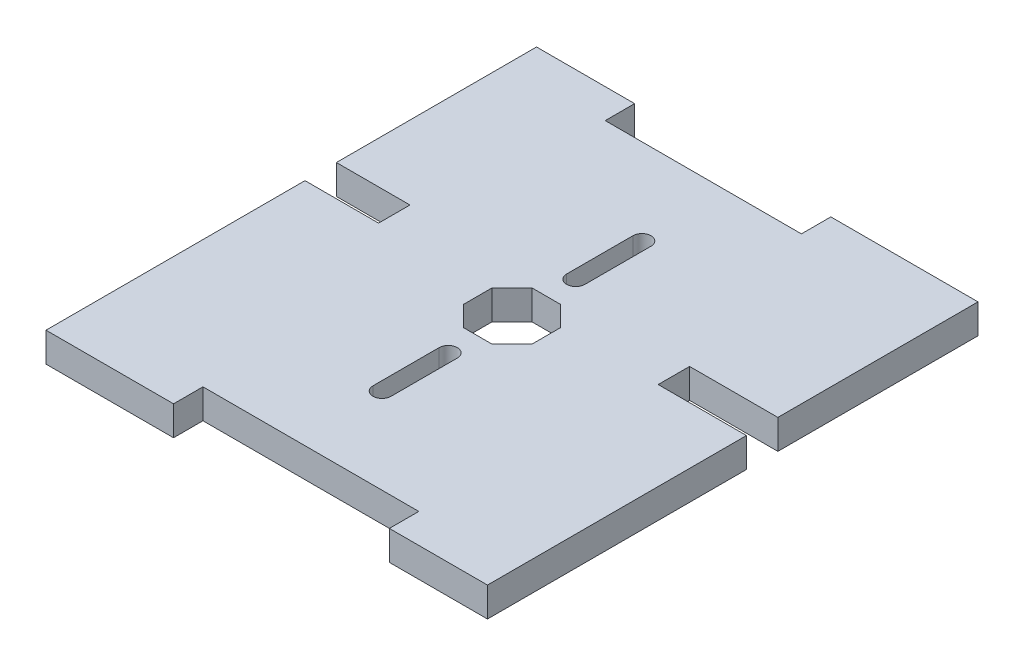
from build123d import *

# Parameters (mm, degrees)
SKETCH1_W           = 45
SKETCH1_H           = 50
BOSS_EXTRUDE1_DEPTH = 3
SKETCH2_W           = 20
SKETCH2_H           = 3
SKETCH2_W_2         = 22
SKETCH2_W_3         = 7.5
SKETCH2_W_4         = 9
CUT_EXTRUDE1_DEPTH  = 4
SKETCH4_W           = 7.5
SKETCH4_H           = 0.1
SKETCH4_W_2         = 9
CUT_EXTRUDE2_DEPTH  = 4


with BuildPart() as part:
    # Sketch1 → Boss-Extrude1 (new body)
    with BuildSketch(Plane(origin=(0, 0, 0), x_dir=(1, 0, 0), z_dir=(0, 1, 0))):
        with Locations((22.5, 25)):
            Rectangle(SKETCH1_W, SKETCH1_H)
    extrude(amount=BOSS_EXTRUDE1_DEPTH)

    # Sketch2 → Cut-Extrude1 (cut, through all)
    with BuildSketch(Plane(origin=(0, 3, 0), x_dir=(1, 0, 0), z_dir=(0, 1, 0))):
        with Locations((20, 48.5)):
            Rectangle(SKETCH2_W, SKETCH2_H)
        with Locations((24, 1.5)):
            Rectangle(SKETCH2_W_2, SKETCH2_H)
        with Locations((3.75, 28)):
            Rectangle(SKETCH2_W_3, SKETCH2_H)
        with Locations((40.5, 28)):
            Rectangle(SKETCH2_W_4, SKETCH2_H)
        Polygon((21.050252532, 21.5), (23.949747468, 21.5), (26, 23.550252532), (26, 26.449747468), (23.949747468, 28.5), (21.050252532, 28.5), (19, 26.449747468), (19, 23.550252532), align=None)
        with BuildLine():
            Line((21.575, 31.5), (21.575, 38.25))
            ThreePointArc((21.575, 38.25), (22.5, 39.175), (23.425, 38.25))
            Line((23.425, 38.25), (23.425, 31.5))
            ThreePointArc((23.425, 31.5), (22.5, 30.575), (21.575, 31.5))
        make_face()
        with BuildLine():
            Line((23.425, 18.5), (23.425, 11.75))
            ThreePointArc((23.425, 11.75), (22.5, 10.825), (21.575, 11.75))
            Line((21.575, 11.75), (21.575, 18.5))
            ThreePointArc((21.575, 18.5), (22.5, 19.425), (23.425, 18.5))
        make_face()
    extrude(amount=-CUT_EXTRUDE1_DEPTH, mode=Mode.SUBTRACT)

    # Sketch4 → Cut-Extrude2 (cut, through all)
    with BuildSketch(Plane(origin=(0, 3, 0), x_dir=(1, 0, 0), z_dir=(0, 1, 0))):
        with Locations((3.75, 29.55)):
            Rectangle(SKETCH4_W, SKETCH4_H)
        with Locations((3.75, 26.45)):
            Rectangle(SKETCH4_W, SKETCH4_H)
        with Locations((40.5, 26.45)):
            Rectangle(SKETCH4_W_2, SKETCH4_H)
        with Locations((40.5, 29.55)):
            Rectangle(SKETCH4_W_2, SKETCH4_H)
    extrude(amount=-CUT_EXTRUDE2_DEPTH, mode=Mode.SUBTRACT)


solid = part.part
